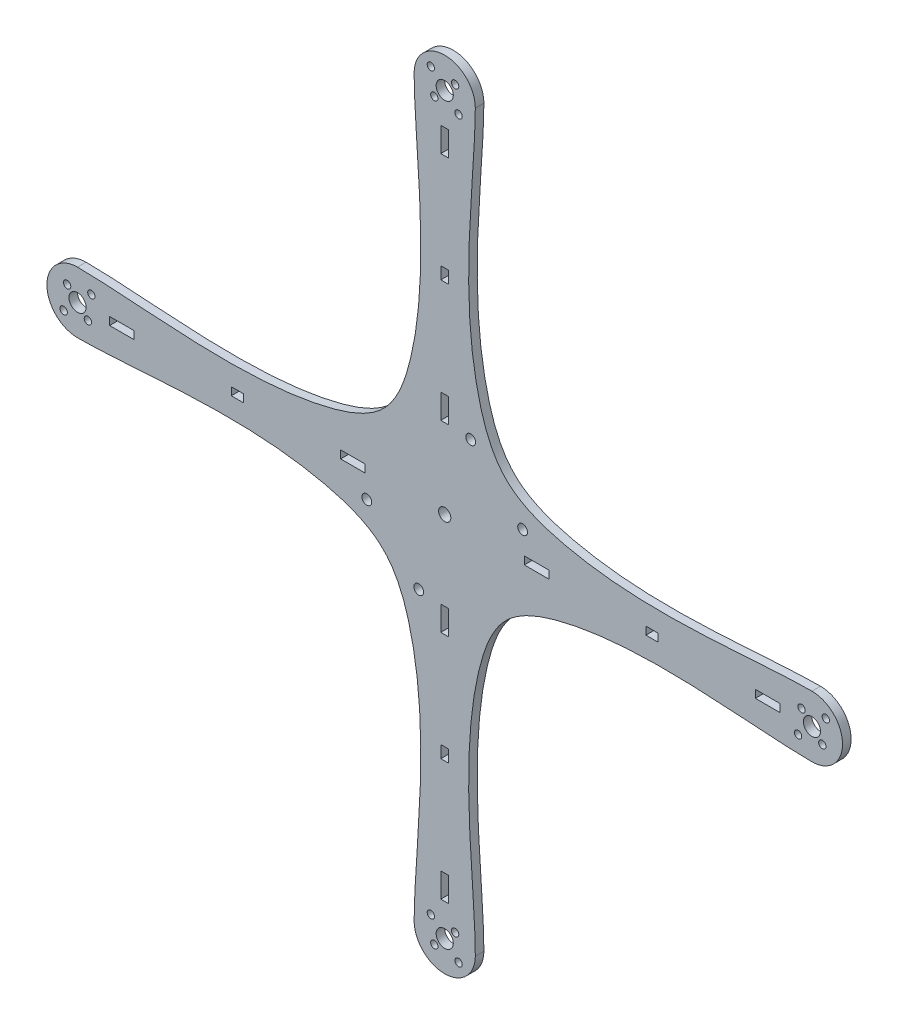
from build123d import *

# Parameters (mm, degrees)
SKETCH1_R           = 1.5
SKETCH1_R_2         = 3.5
SKETCH1_R_3         = 2.5
SKETCH1_R_4         = 2
SKETCH1_W           = 3.2
SKETCH1_H           = 10
SKETCH1_W_2         = 10
SKETCH1_H_2         = 3.2
SKETCH1_W_3         = 5
SKETCH1_H_3         = 5
BOSS_EXTRUDE1_DEPTH = 3.5


with BuildPart() as part:
    # Sketch1 → Boss-Extrude1 (new body)
    with BuildSketch(Plane.XY):
        with BuildLine():
            ThreePointArc((-12.5, -150), (0, -162.5), (12.5, -150))
            add(Edge.make_bspline(
                [(150, -12.5), (125.11944581, -12.5), (72.846772211, -3.708905535), (22.345008274, -22.34366752), (3.707229254, -72.858505534), (12.5, -125.012148344), (12.5, -150)],
                knots=[0, 0, 0, 0, 0.361155478, 0.451426989, 0.5416985, 0.902853978, 0.902853978, 0.902853978, 0.902853978], degree=3))
            ThreePointArc((150, -12.5), (162.5, 0), (150, 12.5))
            add(Edge.make_bspline(
                [(12.5, 150), (12.5, 125.11944581), (3.708905535, 72.846772211), (22.34366752, 22.345008274), (72.858505534, 3.707229254), (125.012148344, 12.5), (150, 12.5)],
                knots=[0, 0, 0, 0, 0.361155478, 0.451426989, 0.5416985, 0.902853978, 0.902853978, 0.902853978, 0.902853978], degree=3))
            ThreePointArc((12.5, 150), (0, 162.5), (-12.5, 150))
            add(Edge.make_bspline(
                [(-150, 12.5), (-125.11944581, 12.5), (-72.846772211, 3.708905535), (-22.345008274, 22.34366752), (-3.707229254, 72.858505534), (-12.5, 125.012148344), (-12.5, 150)],
                knots=[0, 0, 0, 0, 0.361155478, 0.451426989, 0.5416985, 0.902853978, 0.902853978, 0.902853978, 0.902853978], degree=3))
            ThreePointArc((-150, 12.5), (-162.5, 0), (-150, -12.5))
            add(Edge.make_bspline(
                [(-12.5, -150), (-12.5, -125.11944581), (-3.708905535, -72.846772211), (-22.34366752, -22.345008274), (-72.858505534, -3.707229254), (-125.012148344, -12.5), (-150, -12.5)],
                knots=[0, 0, 0, 0, 0.361155478, 0.451426989, 0.5416985, 0.902853978, 0.902853978, 0.902853978, 0.902853978], degree=3))
        make_face()
        with Locations((-155.656854249, -5.656854249)):
            Circle(SKETCH1_R, mode=Mode.SUBTRACT)
        with Locations((-144.343145751, 5.656854249)):
            Circle(SKETCH1_R, mode=Mode.SUBTRACT)
        with Locations((-145.757359313, -4.242640687)):
            Circle(SKETCH1_R, mode=Mode.SUBTRACT)
        with Locations((-154.242640687, 4.242640687)):
            Circle(SKETCH1_R, mode=Mode.SUBTRACT)
        with Locations((-5.656854249, 155.656854249)):
            Circle(SKETCH1_R, mode=Mode.SUBTRACT)
        with Locations((-4.242640687, 145.757359313)):
            Circle(SKETCH1_R, mode=Mode.SUBTRACT)
        with Locations((5.656854249, 144.343145751)):
            Circle(SKETCH1_R, mode=Mode.SUBTRACT)
        with Locations((4.242640687, 154.242640687)):
            Circle(SKETCH1_R, mode=Mode.SUBTRACT)
        with Locations((155.656854249, 5.65685425)):
            Circle(SKETCH1_R, mode=Mode.SUBTRACT)
        with Locations((145.757359313, 4.242640687)):
            Circle(SKETCH1_R, mode=Mode.SUBTRACT)
        with Locations((144.343145751, -5.656854249)):
            Circle(SKETCH1_R, mode=Mode.SUBTRACT)
        with Locations((154.242640687, -4.242640687)):
            Circle(SKETCH1_R, mode=Mode.SUBTRACT)
        with Locations((5.656854249, -155.656854249)):
            Circle(SKETCH1_R, mode=Mode.SUBTRACT)
        with Locations((4.242640687, -145.757359313)):
            Circle(SKETCH1_R, mode=Mode.SUBTRACT)
        with Locations((-5.656854249, -144.343145751)):
            Circle(SKETCH1_R, mode=Mode.SUBTRACT)
        with Locations((-4.242640687, -154.242640687)):
            Circle(SKETCH1_R, mode=Mode.SUBTRACT)
        with Locations((-150, 0)):
            Circle(SKETCH1_R_2, mode=Mode.SUBTRACT)
        with Locations((0, 150)):
            Circle(SKETCH1_R_2, mode=Mode.SUBTRACT)
        with Locations((150, 0)):
            Circle(SKETCH1_R_2, mode=Mode.SUBTRACT)
        with Locations((0, -150)):
            Circle(SKETCH1_R_2, mode=Mode.SUBTRACT)
        Circle(SKETCH1_R_3, mode=Mode.SUBTRACT)
        with Locations((10.606601718, 31.819805153)):
            Circle(SKETCH1_R_4, mode=Mode.SUBTRACT)
        with Locations((31.819805153, 10.606601718)):
            Circle(SKETCH1_R_4, mode=Mode.SUBTRACT)
        with Locations((-10.606601718, -31.819805153)):
            Circle(SKETCH1_R_4, mode=Mode.SUBTRACT)
        with Locations((-31.819805153, -10.606601718)):
            Circle(SKETCH1_R_4, mode=Mode.SUBTRACT)
        with Locations((0, -37.5)):
            Rectangle(SKETCH1_W, SKETCH1_H, mode=Mode.SUBTRACT)
        with Locations((-37.5, 0)):
            Rectangle(SKETCH1_W_2, SKETCH1_H_2, mode=Mode.SUBTRACT)
        with Locations((0, 37.5)):
            Rectangle(SKETCH1_W, SKETCH1_H, mode=Mode.SUBTRACT)
        with Locations((37.5, 0)):
            Rectangle(SKETCH1_W_2, SKETCH1_H_2, mode=Mode.SUBTRACT)
        with Locations((0, -131.870885898)):
            Rectangle(SKETCH1_W, SKETCH1_H, mode=Mode.SUBTRACT)
        with Locations((-131.870885898, 0)):
            Rectangle(SKETCH1_W_2, SKETCH1_H_2, mode=Mode.SUBTRACT)
        with Locations((0, 131.870885898)):
            Rectangle(SKETCH1_W, SKETCH1_H, mode=Mode.SUBTRACT)
        with Locations((131.870885898, 0)):
            Rectangle(SKETCH1_W_2, SKETCH1_H_2, mode=Mode.SUBTRACT)
        with Locations((-84.685442949, 0)):
            Rectangle(SKETCH1_W_3, SKETCH1_H_2, mode=Mode.SUBTRACT)
        with Locations((0, -84.685442949)):
            Rectangle(SKETCH1_W, SKETCH1_H_3, mode=Mode.SUBTRACT)
        with Locations((0, 84.685442949)):
            Rectangle(SKETCH1_W, SKETCH1_H_3, mode=Mode.SUBTRACT)
        with Locations((84.685442949, 0)):
            Rectangle(SKETCH1_W_3, SKETCH1_H_2, mode=Mode.SUBTRACT)
    extrude(amount=BOSS_EXTRUDE1_DEPTH)


solid = part.part
